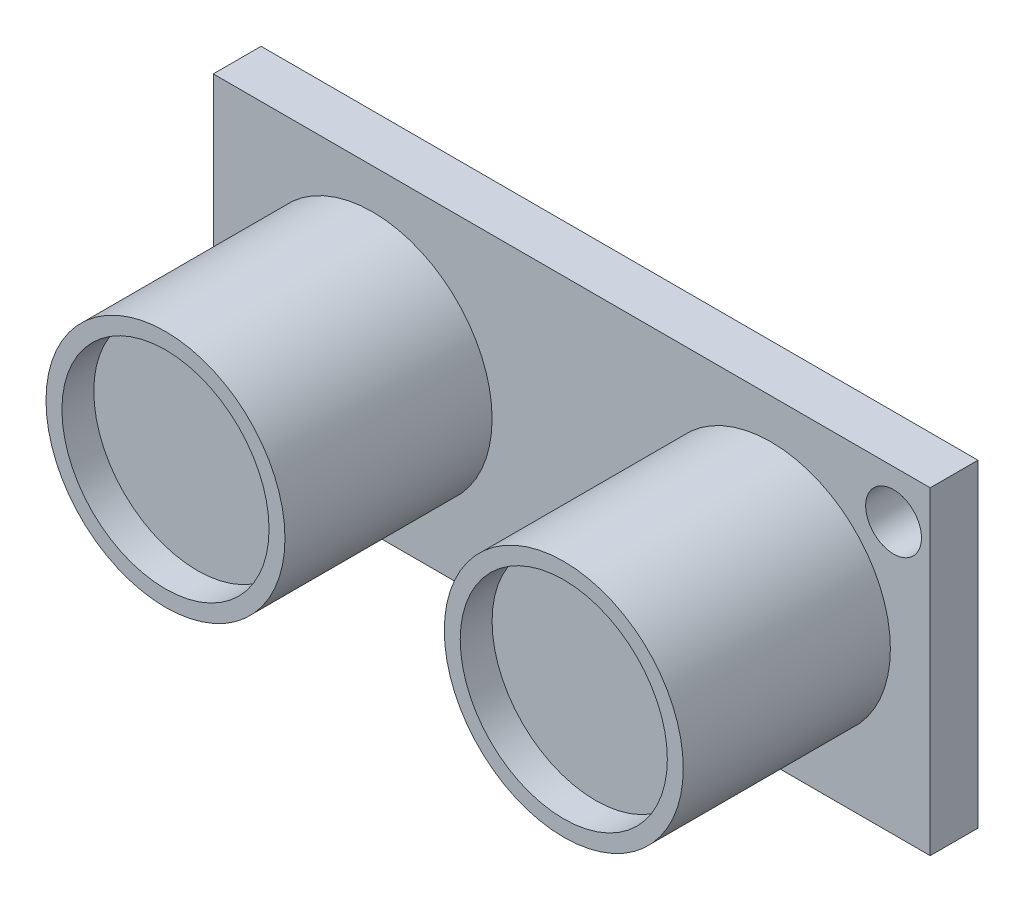
from build123d import *

# Parameters (mm, degrees)
SKETCH_1_W               = 45
SKETCH_1_H               = 20
EXTRUDE_1_DEPTH          = 3
SKETCH_2_R               = 7.5
EXTRUDE_2_DEPTH          = 13
SKETCH_3_R               = 1.75
CUT_EXTRUDE_1_DEPTH      = 14
CUT_EXTRUDE_1_DEPTH_BACK = 4
SKETCH_4_R               = 6.5
CUT_EXTRUDE_2_DEPTH      = 2


with BuildPart() as part:
    # 草图1 → 凸台-拉伸1 (new body)
    with BuildSketch(Plane.XY):
        Rectangle(SKETCH_1_W, SKETCH_1_H)
    extrude(amount=EXTRUDE_1_DEPTH)

    # 草图2 → 凸台-拉伸2 (add)
    with BuildSketch(Plane.XY.offset(3)):
        with Locations((12.5, 0)):
            Circle(SKETCH_2_R)
        with Locations((-12.5, 0)):
            Circle(SKETCH_2_R)
    extrude(amount=EXTRUDE_2_DEPTH)

    # 草图3 → 切除-拉伸1 (cut, two sides)
    with BuildSketch(Plane.XY.offset(3)) as cut_extrude_1_sk:
        with Locations((20.2, 7)):
            Circle(SKETCH_3_R)
        with Locations((-20.2, -7)):
            Circle(SKETCH_3_R)
    extrude(amount=CUT_EXTRUDE_1_DEPTH, mode=Mode.SUBTRACT)
    extrude(cut_extrude_1_sk.sketch, amount=-CUT_EXTRUDE_1_DEPTH_BACK, mode=Mode.SUBTRACT)

    # 草图4 → 切除-拉伸2 (cut)
    with BuildSketch(Plane.XY.offset(16)):
        with Locations((-12.5, 0)):
            Circle(SKETCH_4_R)
        with Locations((12.5, 0)):
            Circle(SKETCH_4_R)
    extrude(amount=-CUT_EXTRUDE_2_DEPTH, mode=Mode.SUBTRACT)


solid = part.part
